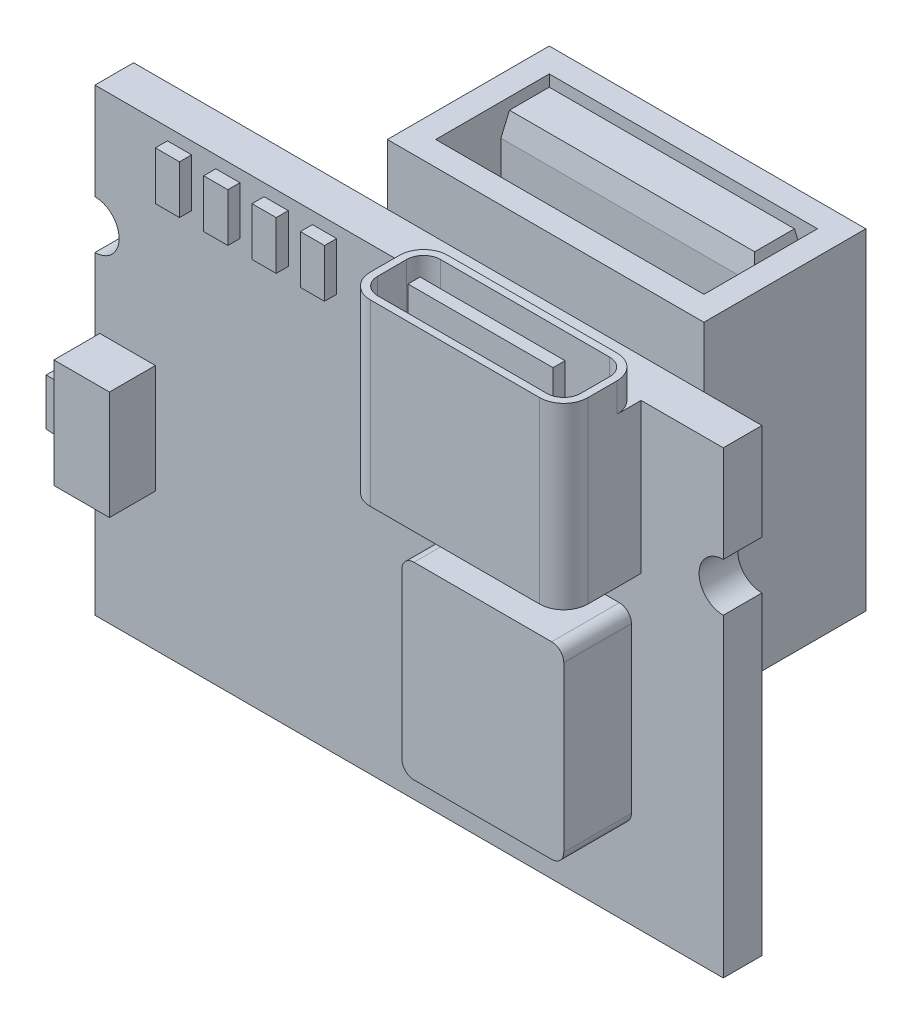
from build123d import *

# Parameters (mm, degrees)
ESBO_O1_W                = 26
ESBO_O1_H                = 19
RESSALTO_EXTRUS_O1_DEPTH = 1.6
ESBO_O2_W                = 1
ESBO_O2_H                = 2
RESSALTO_EXTRUS_O2_DEPTH = 0.5
ESBO_O3_W                = 9
ESBO_O3_H                = 7.4
RESSALTO_EXTRUS_O3_DEPTH = 3.2
FILETE1_R                = 1
FILETE7_R                = 1
CORTE_EXTRUS_O1_DEPTH    = 5.2
RESSALTO_EXTRUS_O4_REACH = 22.2
ESBO_O5_W                = 6
ESBO_O5_H                = 0.5
ESBO_O6_W                = 6.7
ESBO_O6_H                = 7.8
RESSALTO_EXTRUS_O5_DEPTH = 2.8
FILETE8_R                = 0.5
ESBO_O7_W                = 2.3
ESBO_O7_H                = 4.5
RESSALTO_EXTRUS_O6_DEPTH = 1.9
ESBO_O8_W                = 0.8
ESBO_O8_H                = 2
RESSALTO_EXTRUS_O7_DEPTH = 0.9
RESSALTO_EXTRUS_O7_TAPER = 2
ESBO_O9_W                = 13.1
ESBO_O9_H                = 13.7
RESSALTO_EXTRUS_O8_DEPTH = 8
ESBO_O10_W               = 13.1
ESBO_O10_H               = 1.3
CORTE_EXTRUS_O2_DEPTH    = 9
ESBO_O11_W               = 11.1
ESBO_O11_H               = 4.7
CORTE_EXTRUS_O3_DEPTH    = 9
RESSALTO_EXTRUS_O9_REACH = 22.2
ESBO_O12_W               = 10.5
ESBO_O12_H               = 2
CHANFRO1_SIZE            = 1
CHANFRO1_SIZE2           = 0.176326981
CHANFRO1_PART_2_SIZE     = 1
CHANFRO1_PART_2_SIZE2    = 0.176326981
CHANFRO1_PART_3_SIZE     = 1
CHANFRO1_PART_3_SIZE2    = 0.176326981
CHANFRO1_PART_4_SIZE     = 1
CHANFRO1_PART_4_SIZE2    = 0.176326981
CORTE_EXTRUS_O4_REACH    = 11.6
ESBO_O13_R               = 1


with BuildPart() as part:
    # Esboço1 → Ressalto-extrusão1 (new body)
    with BuildSketch(Plane.XY):
        with Locations((-18.344966746, 5.985294118)):
            Rectangle(ESBO_O1_W, ESBO_O1_H)
    extrude(amount=RESSALTO_EXTRUS_O1_DEPTH)

    # Esboço2 → Ressalto-extrusão2 (add)
    with BuildSketch(Plane.XY.offset(1.6)):
        with Locations((-27.844966746, 13.985294118)):
            Rectangle(ESBO_O2_W, ESBO_O2_H)
        with Locations((-25.844966746, 13.985294118)):
            Rectangle(ESBO_O2_W, ESBO_O2_H)
        with Locations((-23.844966746, 13.985294118)):
            Rectangle(ESBO_O2_W, ESBO_O2_H)
        with Locations((-21.844966746, 13.985294118)):
            Rectangle(ESBO_O2_W, ESBO_O2_H)
    extrude(amount=RESSALTO_EXTRUS_O2_DEPTH)

    # Esboço3 → Ressalto-extrusão3 (add)
    with BuildSketch(Plane.XY.offset(1.6)):
        with Locations((-13.244966746, 12.985294118)):
            Rectangle(ESBO_O3_W, ESBO_O3_H)
    extrude(amount=RESSALTO_EXTRUS_O3_DEPTH)

    # Filete1
    filete1_edges = [part.edges().sort_by_distance(p)[0] for p in [
        (-8.744966746, 12.985294118, 4.8),
    ]]
    fillet(filete1_edges, radius=FILETE1_R)

    # Filete7
    filete7_edges = [part.edges().sort_by_distance(p)[0] for p in [
        (-17.744966746, 16.085294118, 1.6),
        (-8.744966746, 16.085294118, 1.6),
        (-17.744966746, 12.985294118, 4.8),
    ]]
    fillet(filete7_edges, radius=FILETE7_R)

    # Esboço4 → Corte-extrusão1 (cut)
    with BuildSketch(Plane(origin=(0, 16.685294118, 0), x_dir=(1, 0, 0), z_dir=(0, 1, 0))):
        with BuildLine():
            Line((-9.744966746, -1.9), (-16.744966746, -1.9))
            ThreePointArc((-16.744966746, -1.9), (-17.239941493, -2.105025253), (-17.444966746, -2.6))
            Line((-17.444966746, -2.6), (-17.444966746, -3.8))
            ThreePointArc((-17.444966746, -3.8), (-17.239941493, -4.294974747), (-16.744966746, -4.5))
            Line((-16.744966746, -4.5), (-9.744966746, -4.5))
            ThreePointArc((-9.744966746, -4.5), (-9.249991999, -4.294974747), (-9.044966746, -3.8))
            Line((-9.044966746, -3.8), (-9.044966746, -2.6))
            ThreePointArc((-9.044966746, -2.6), (-9.249991999, -2.105025253), (-9.744966746, -1.9))
        make_face()
    extrude(amount=-CORTE_EXTRUS_O1_DEPTH, mode=Mode.SUBTRACT)

    # Esboço5 → Ressalto-extrusão4 (add, up to next)
    with BuildSketch(Plane(origin=(0, 16.685294118, 0), x_dir=(1, 0, 0), z_dir=(0, 1, 0)), mode=Mode.PRIVATE) as ressalto_extrus_o4_sk1:
        with Locations((-13.539619271, -3.2)):
            Rectangle(ESBO_O5_W, ESBO_O5_H)
    ressalto_extrus_o4_tool1 = extrude(ressalto_extrus_o4_sk1.sketch, amount=-RESSALTO_EXTRUS_O4_REACH, mode=Mode.PRIVATE) - part.part
    add(ressalto_extrus_o4_tool1.solids().sort_by_distance((-13.539619, 16.685294, 3.2))[0])

    # Esboço6 → Ressalto-extrusão5 (add)
    with BuildSketch(Plane.XY.offset(1.6)):
        with Locations((-12.494966746, 3.885294118)):
            Rectangle(ESBO_O6_W, ESBO_O6_H)
    extrude(amount=RESSALTO_EXTRUS_O5_DEPTH)

    # Filete8
    filete8_edges = [part.edges().sort_by_distance(p)[0] for p in [
        (-15.844966746, 7.785294118, 3),
        (-15.844966746, -0.014705882, 3),
        (-9.144966746, -0.014705882, 3),
        (-9.144966746, 7.785294118, 3),
    ]]
    fillet(filete8_edges, radius=FILETE8_R)

    # Esboço7 → Ressalto-extrusão6 (add)
    with BuildSketch(Plane.XY.offset(1.6)):
        with Locations((-29.994966746, 4.435294118)):
            Rectangle(ESBO_O7_W, ESBO_O7_H)
    extrude(amount=RESSALTO_EXTRUS_O6_DEPTH)

    # Esboço8 → Ressalto-extrusão7 (add)
    with BuildSketch(Plane.ZY.offset(31.144966746)):
        with Locations((2.55, 4.435294118)):
            Rectangle(ESBO_O8_W, ESBO_O8_H)
    extrude(amount=RESSALTO_EXTRUS_O7_DEPTH, taper=RESSALTO_EXTRUS_O7_TAPER)

    # Esboço9 → Ressalto-extrusão8 (add)
    with BuildSketch(Plane(origin=(0, 0, 0), x_dir=(-1, 0, 0), z_dir=(0, 0, -1))):
        with Locations((15.594966746, 9.835294118)):
            Rectangle(ESBO_O9_W, ESBO_O9_H)
    extrude(amount=RESSALTO_EXTRUS_O8_DEPTH)

    # Esboço10 → Corte-extrusão2 (cut)
    with BuildSketch(Plane(origin=(0, 16.685294118, 0), x_dir=(1, 0, 0), z_dir=(0, 1, 0))):
        with Locations((-15.594966746, 0.65)):
            Rectangle(ESBO_O10_W, ESBO_O10_H)
    extrude(amount=-CORTE_EXTRUS_O2_DEPTH, mode=Mode.SUBTRACT)

    # Esboço11 → Corte-extrusão3 (cut)
    with BuildSketch(Plane(origin=(0, 16.685294118, 0), x_dir=(1, 0, 0), z_dir=(0, 1, 0))):
        with Locations((-15.594966746, 4.65)):
            Rectangle(ESBO_O11_W, ESBO_O11_H)
    extrude(amount=-CORTE_EXTRUS_O3_DEPTH, mode=Mode.SUBTRACT)

    # Esboço12 → Ressalto-extrusão9 (add, up to next)
    with BuildSketch(Plane(origin=(0, 16.685294118, 0), x_dir=(1, 0, 0), z_dir=(0, 1, 0)), mode=Mode.PRIVATE) as ressalto_extrus_o9_sk1:
        with Locations((-15.594966746, 5.7)):
            Rectangle(ESBO_O12_W, ESBO_O12_H)
    ressalto_extrus_o9_tool1 = extrude(ressalto_extrus_o9_sk1.sketch, amount=-RESSALTO_EXTRUS_O9_REACH, mode=Mode.PRIVATE) - part.part
    add(ressalto_extrus_o9_tool1.solids().sort_by_distance((-15.594967, 16.685294, -5.7))[0])

    # Chanfro1
    chanfro1_edges = [part.edges().sort_by_distance(p)[0] for p in [
        (-20.844966746, 16.685294118, -5.7),
    ]]
    chanfro1_side = [part.faces().sort_by_distance(p)[0] for p in [
        (-20.844966746, 12.185294118, -5.7),
    ]]
    chamfer(chanfro1_edges, length=CHANFRO1_SIZE, length2=CHANFRO1_SIZE2, reference=chanfro1_side[0])

    # Chanfro1 part 2
    chanfro1_part_2_edges = [part.edges().sort_by_distance(p)[0] for p in [
        (-15.594966746, 16.685294118, -4.7),
    ]]
    chanfro1_part_2_side = [part.faces().sort_by_distance(p)[0] for p in [
        (-15.594966746, 12.185294118, -4.7),
    ]]
    chamfer(chanfro1_part_2_edges, length=CHANFRO1_PART_2_SIZE, length2=CHANFRO1_PART_2_SIZE2, reference=chanfro1_part_2_side[0])

    # Chanfro1 part 3
    chanfro1_part_3_edges = [part.edges().sort_by_distance(p)[0] for p in [
        (-10.344966746, 16.685294118, -5.7),
    ]]
    chanfro1_part_3_side = [part.faces().sort_by_distance(p)[0] for p in [
        (-10.344966746, 12.185294118, -5.7),
    ]]
    chamfer(chanfro1_part_3_edges, length=CHANFRO1_PART_3_SIZE, length2=CHANFRO1_PART_3_SIZE2, reference=chanfro1_part_3_side[0])

    # Chanfro1 part 4
    chanfro1_part_4_edges = [part.edges().sort_by_distance(p)[0] for p in [
        (-15.594966746, 16.685294118, -6.7),
    ]]
    chanfro1_part_4_side = [part.faces().sort_by_distance(p)[0] for p in [
        (-15.594966746, 12.185294118, -6.7),
    ]]
    chamfer(chanfro1_part_4_edges, length=CHANFRO1_PART_4_SIZE, length2=CHANFRO1_PART_4_SIZE2, reference=chanfro1_part_4_side[0])

    # Esboço13 → Corte-extrusão4 (cut, up to next)
    with BuildSketch(Plane.XY.offset(1.6), mode=Mode.PRIVATE) as corte_extrus_o4_sk1:
        with Locations((-31.344966746, 10.485294118)):
            Circle(ESBO_O13_R)
    corte_extrus_o4_tool1 = extrude(corte_extrus_o4_sk1.sketch, amount=-CORTE_EXTRUS_O4_REACH, mode=Mode.PRIVATE) & part.part
    add(corte_extrus_o4_tool1.solids().sort_by_distance((-31.344967, 10.485294, 1.6))[0], mode=Mode.SUBTRACT)
    # Esboço13 → Corte-extrusão4 (cut, up to next)
    with BuildSketch(Plane.XY.offset(1.6), mode=Mode.PRIVATE) as corte_extrus_o4_sk2:
        with Locations((-5.344966746, 10.485294118)):
            Circle(ESBO_O13_R)
    corte_extrus_o4_tool2 = extrude(corte_extrus_o4_sk2.sketch, amount=-CORTE_EXTRUS_O4_REACH, mode=Mode.PRIVATE) & part.part
    add(corte_extrus_o4_tool2.solids().sort_by_distance((-5.344967, 10.485294, 1.6))[0], mode=Mode.SUBTRACT)


solid = part.part
